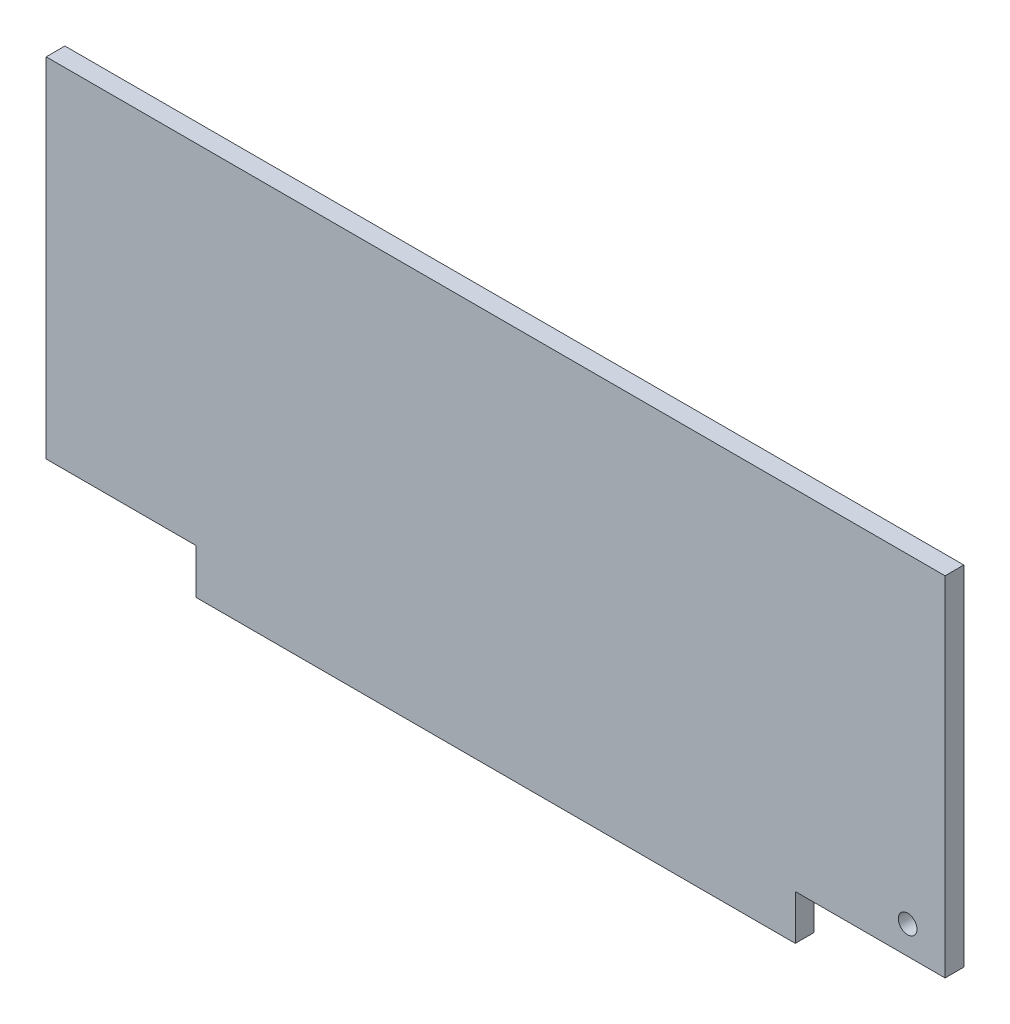
from build123d import *

# Parameters (mm, degrees)
ESQUISSE1_W             = 480
ESQUISSE1_H             = 210
BOSS_EXTRU_1_DEPTH      = 10
ESQUISSE2_W             = 80
ESQUISSE2_H             = 24
ENL_V_MAT_EXTRU_1_DEPTH = 11
ESQUISSE3_R             = 5
ENL_V_MAT_EXTRU_2_DEPTH = 11


with BuildPart() as part:
    # Esquisse1 → Boss.-Extru.1 (new body)
    with BuildSketch(Plane.XY):
        with Locations((-50, 0)):
            Rectangle(ESQUISSE1_W, ESQUISSE1_H)
    extrude(amount=BOSS_EXTRU_1_DEPTH)

    # Esquisse2 → Enlèv. mat.-Extru.1 (cut, through all)
    with BuildSketch(Plane.XY.offset(10)):
        with Locations((150, -93)):
            Rectangle(ESQUISSE2_W, ESQUISSE2_H)
        with Locations((-250, -93)):
            Rectangle(ESQUISSE2_W, ESQUISSE2_H)
    extrude(amount=-ENL_V_MAT_EXTRU_1_DEPTH, mode=Mode.SUBTRACT)

    # Esquisse3 → Enlèv. mat.-Extru.2 (cut, through all)
    with BuildSketch(Plane.XY.offset(10)):
        with Locations((170, -66)):
            Circle(ESQUISSE3_R)
    extrude(amount=-ENL_V_MAT_EXTRU_2_DEPTH, mode=Mode.SUBTRACT)


solid = part.part
